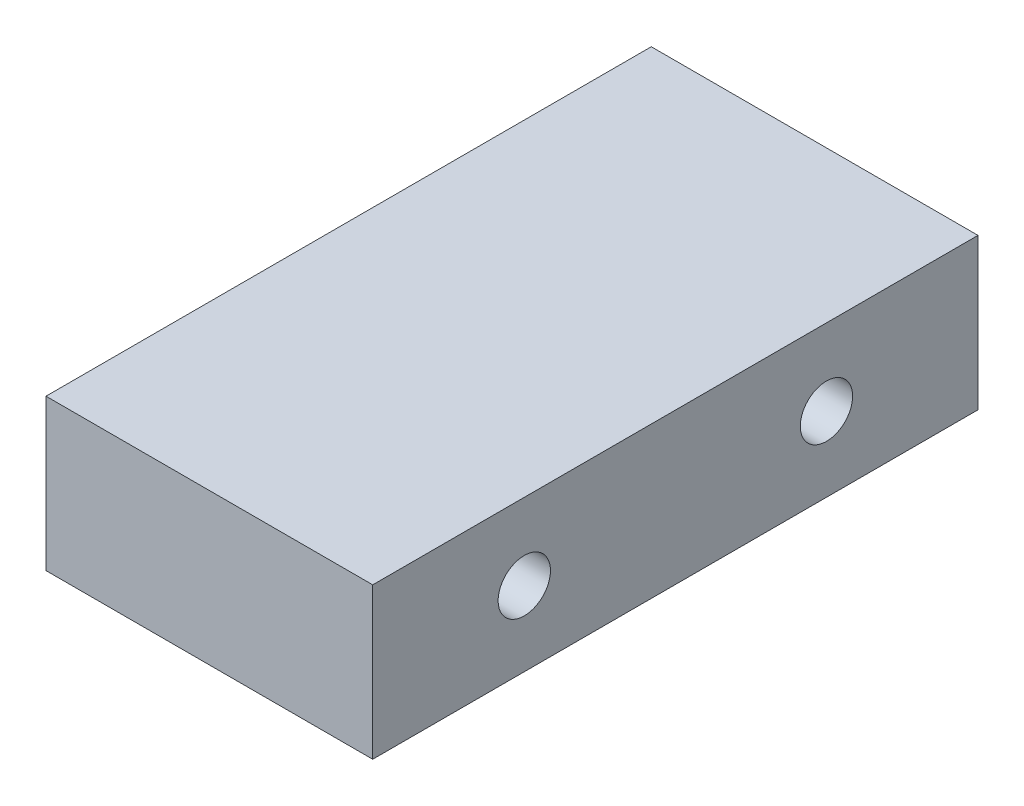
from build123d import *

# Parameters (mm, degrees)
BOSS_EXTRUDE1_DEPTH      = 19.09
BOSS_EXTRUDE1_DEPTH_BACK = 19.09
CUT_EXTRUDE1_DEPTH       = 32.021081541
SKETCH3_R                = 1.125
CUT_EXTRUDE2_DEPTH       = 6.35
SKETCH4_R                = 1.65
CUT_EXTRUDE3_DEPTH       = 15


with BuildPart() as part:
    # Sketch1 → Boss-Extrude1 (new, two sides: drawn at the far end of the back side and taken through both)
    with BuildSketch(Plane.XY.offset(-BOSS_EXTRUDE1_DEPTH_BACK)):
        Polygon((-3.18, 0), (3.18, 0), (3.18, 10.34), (17.43, 10.34), (17.43, 19.87), (-3.18, 19.87), align=None)
    extrude(amount=BOSS_EXTRUDE1_DEPTH + BOSS_EXTRUDE1_DEPTH_BACK)

    # Sketch2 → Cut-Extrude1 (cut, through all)
    with BuildSketch(Plane(origin=(3.18, 0, 0), x_dir=(0, 0, -1), z_dir=(1, 0, 0))):
        Polygon((19.09, 10.34), (6.31, 0), (19.09, 0), align=None)
        Polygon((-19.09, 10.34), (-19.09, 0), (-6.31, 0), align=None)
    extrude(amount=-CUT_EXTRUDE1_DEPTH, mode=Mode.SUBTRACT)

    # Sketch3 → Cut-Extrude2 (cut)
    with BuildSketch(Plane.XZ):
        Circle(SKETCH3_R)
    extrude(amount=-CUT_EXTRUDE2_DEPTH, mode=Mode.SUBTRACT)

    # Sketch4 → Cut-Extrude3 (cut)
    with BuildSketch(Plane(origin=(17.43, 0, 0), x_dir=(0, 0, -1), z_dir=(1, 0, 0))):
        with Locations((9.53, 15.045)):
            Circle(SKETCH4_R)
        with Locations((-9.53, 15.045)):
            Circle(SKETCH4_R)
    extrude(amount=-CUT_EXTRUDE3_DEPTH, mode=Mode.SUBTRACT)


solid = part.part
